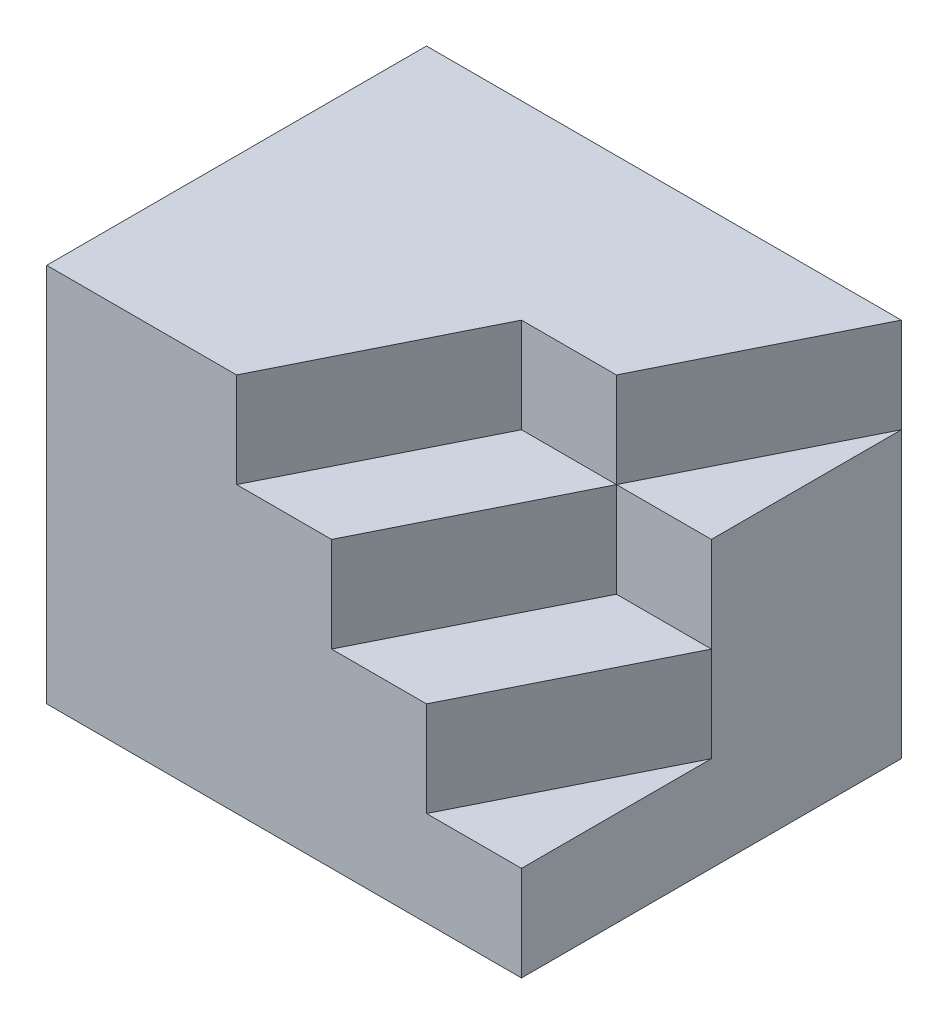
from build123d import *

# Parameters (mm, degrees)
SKETCH_1_W      = 25
SKETCH_1_H      = 20
EXTRUDE_1_DEPTH = 5
EXTRUDE_2_DEPTH = 10
EXTRUDE_4_DEPTH = 20
EXTRUDE_5_DEPTH = 15


with BuildPart() as part:
    # 草圖1 → 填料-伸長1 (new body)
    with BuildSketch(Plane(origin=(0, 0, 0), x_dir=(1, 0, 0), z_dir=(0, 1, 0))):
        Rectangle(SKETCH_1_W, SKETCH_1_H)
    extrude(amount=EXTRUDE_1_DEPTH)

    # 草圖1<3> → 填料-伸長2 (add)
    with BuildSketch(Plane(origin=(0, 0, 0), x_dir=(1, 0, 0), z_dir=(0, 1, 0))):
        Polygon((7.5, -10), (12.5, 0), (12.5, 10), (-12.5, 10), (-12.5, -10), align=None)
    extrude(amount=EXTRUDE_2_DEPTH)

    # 草圖1<5> → 填料-伸長4 (add)
    with BuildSketch(Plane(origin=(0, 0, 0), x_dir=(1, 0, 0), z_dir=(0, 1, 0))):
        Polygon((-2.5, -10), (2.5, 0), (7.5, 0), (12.5, 10), (-12.5, 10), (-12.5, -10), align=None)
    extrude(amount=EXTRUDE_4_DEPTH)

    # 草圖1<6> → 填料-伸長5 (add)
    with BuildSketch(Plane(origin=(0, 0, 0), x_dir=(1, 0, 0), z_dir=(0, 1, 0))):
        Polygon((7.5, 0), (2.5, 0), (-2.5, -10), (2.5, -10), align=None)
        Polygon((12.5, 10), (7.5, 0), (12.5, 0), align=None)
    extrude(amount=EXTRUDE_5_DEPTH)


solid = part.part
